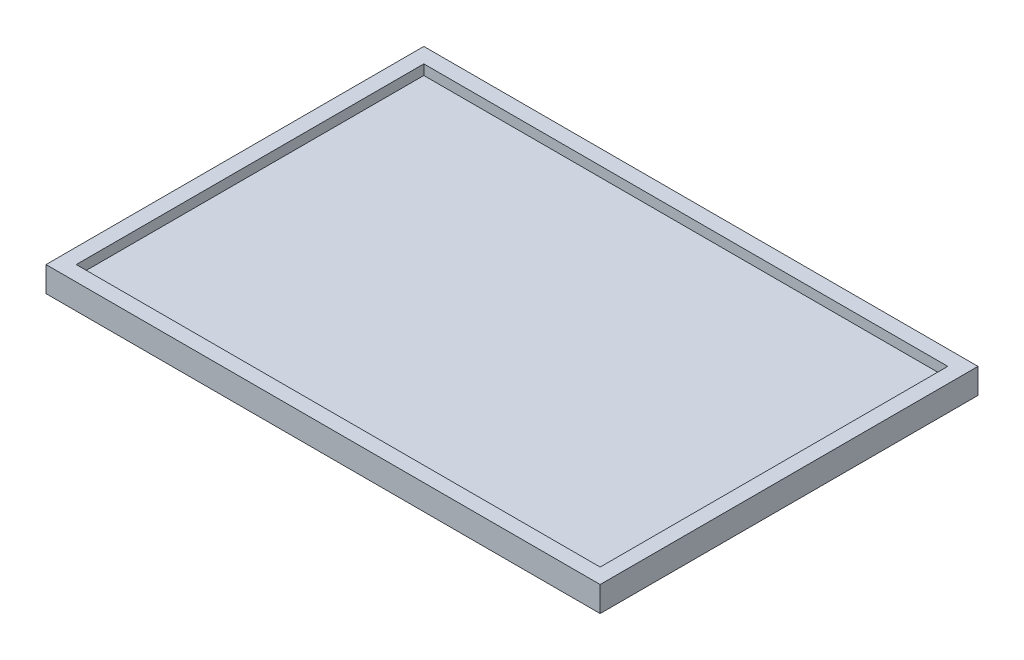
from build123d import *

# Parameters (mm, degrees)
SKETCH1_W           = 110
SKETCH1_H           = 75
BOSS_EXTRUDE1_DEPTH = 5
SKETCH2_W           = 104
SKETCH2_H           = 69
CUT_EXTRUDE1_DEPTH  = 2


with BuildPart() as part:
    # Sketch1 → Boss-Extrude1 (new body)
    with BuildSketch(Plane(origin=(0, 0, 0), x_dir=(1, 0, 0), z_dir=(0, 1, 0))):
        with Locations((5.165579119, -17.688417618)):
            Rectangle(SKETCH1_W, SKETCH1_H)
    extrude(amount=BOSS_EXTRUDE1_DEPTH)

    # Sketch2 → Cut-Extrude1 (cut)
    with BuildSketch(Plane(origin=(0, 5, 0), x_dir=(1, 0, 0), z_dir=(0, 1, 0))):
        with Locations((5.165579119, -17.688417618)):
            Rectangle(SKETCH2_W, SKETCH2_H)
    extrude(amount=-CUT_EXTRUDE1_DEPTH, mode=Mode.SUBTRACT)


solid = part.part
